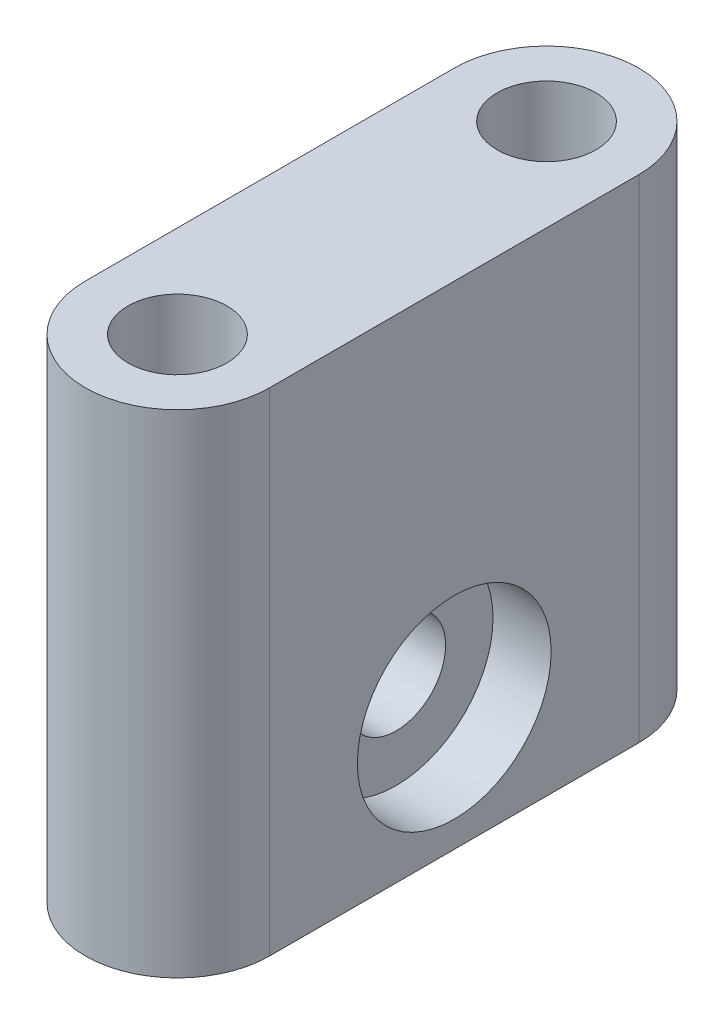
from build123d import *

# Parameters (mm, degrees)
SKETCH8_W                   = 15.875
SKETCH8_H                   = 38.1
BOSS_EXTRUDE2_DEPTH         = 25.4
F_1_4_20_TAPPED_HOLE1_D     = 5.1054
F_1_4_20_TAPPED_HOLE1_DEPTH = 16.51
F_1_4_20_TAPPED_HOLE1_TIP   = 1.533816902
SKETCH10_W                  = 15.875
SKETCH10_H                  = 38.1
CUT_EXTRUDE2_DEPTH          = 26.4
CUT_EXTRUDE5_START          = -19.05
SKETCH13_R                  = 5.000000033
SKETCH13_R_2                = 3.175
CUT_EXTRUDE5_DEPTH          = 3
F_1_4_20_TAPPED_HOLE2_D     = 5.1054
F_1_4_20_TAPPED_HOLE2_DEPTH = 16.51
F_1_4_20_TAPPED_HOLE2_TIP   = 1.533816902


with BuildPart() as part:
    # Sketch8 → Boss-Extrude2 (new body)
    with BuildSketch(Plane(origin=(0, 0, 0), x_dir=(1, 0, 0), z_dir=(0, 1, 0))):
        with Locations((-23.8125, 0)):
            Rectangle(SKETCH8_W, SKETCH8_H)
    extrude(amount=BOSS_EXTRUDE2_DEPTH)

    # 1/4-20 Tapped Hole1
    with Locations(Plane(origin=(0, 25.4, 0), x_dir=(1, 0, 0), z_dir=(0, 1, 0))):
        with Locations((-23.8125, 9.525), (-23.8125, -9.525)):
            Hole(F_1_4_20_TAPPED_HOLE1_D / 2, depth=F_1_4_20_TAPPED_HOLE1_DEPTH)
            with Locations((0, 0, -(F_1_4_20_TAPPED_HOLE1_DEPTH + F_1_4_20_TAPPED_HOLE1_TIP / 2))):  # 118° drill point
                Cone(0, F_1_4_20_TAPPED_HOLE1_D / 2, F_1_4_20_TAPPED_HOLE1_TIP, mode=Mode.SUBTRACT)

    # Sketch10 → Cut-Extrude2 (cut, through all)
    with BuildSketch(Plane(origin=(0, 0, 0), x_dir=(1, 0, 0), z_dir=(0, 1, 0))):
        with Locations((-23.8125, 0)):
            Rectangle(SKETCH10_W, SKETCH10_H)
        with BuildLine():
            Line((-28.575, 9.525), (-28.575, -9.525))
            ThreePointArc((-28.575, -9.525), (-23.8125, -14.2875), (-19.05, -9.525))
            Line((-19.05, -9.525), (-19.05, 9.525))
            ThreePointArc((-19.05, 9.525), (-23.8125, 14.2875), (-28.575, 9.525))
        make_face(mode=Mode.SUBTRACT)
    extrude(amount=CUT_EXTRUDE2_DEPTH, mode=Mode.SUBTRACT)

    # Sketch13 → Cut-Extrude5 (cut)
    with BuildSketch(Plane(origin=(0, 0, 0), x_dir=(0, 0, -1), z_dir=(1, 0, 0)).offset(CUT_EXTRUDE5_START)):
        with Locations((0, 6.35)):
            Circle(SKETCH13_R)
        with Locations((0, 6.35)):
            Circle(SKETCH13_R_2, mode=Mode.SUBTRACT)
        with Locations((0, 6.35)):
            Circle(SKETCH13_R_2)
    extrude(amount=-CUT_EXTRUDE5_DEPTH, mode=Mode.SUBTRACT)

    # 1/4-20 Tapped Hole2
    with Locations(Plane(origin=(-19.05, 0, 0), x_dir=(0, 0, -1), z_dir=(1, 0, 0))):
        with Locations((0, 6.35)):
            Hole(F_1_4_20_TAPPED_HOLE2_D / 2, depth=F_1_4_20_TAPPED_HOLE2_DEPTH)
            with Locations((0, 0, -(F_1_4_20_TAPPED_HOLE2_DEPTH + F_1_4_20_TAPPED_HOLE2_TIP / 2))):  # 118° drill point
                Cone(0, F_1_4_20_TAPPED_HOLE2_D / 2, F_1_4_20_TAPPED_HOLE2_TIP, mode=Mode.SUBTRACT)


solid = part.part
